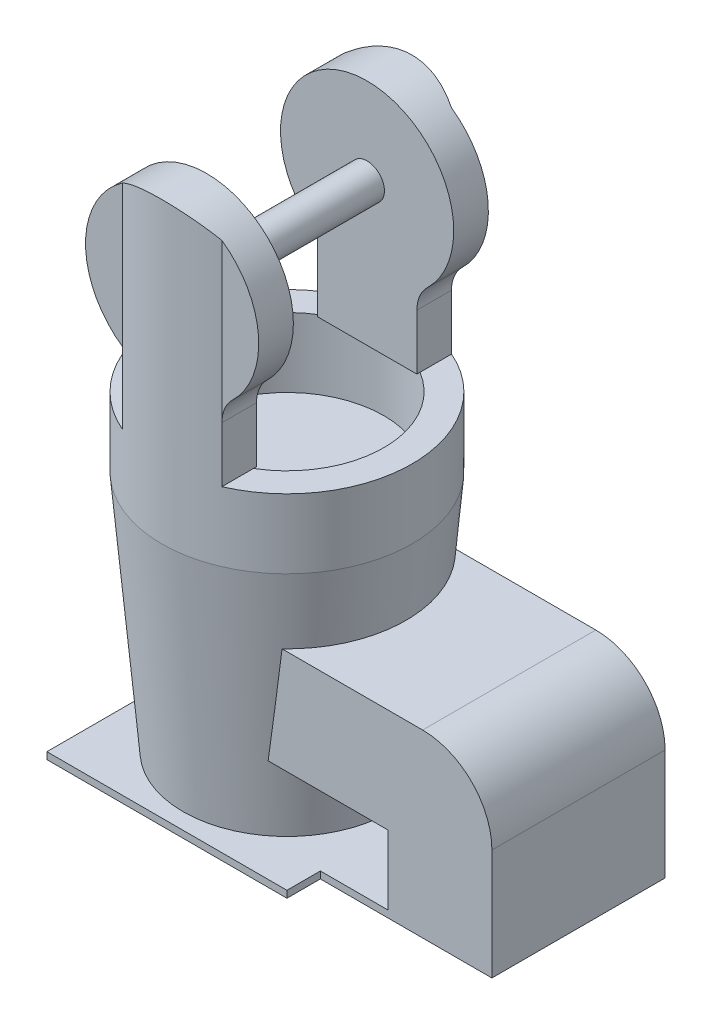
from build123d import *

# Parameters (mm, degrees)
SKETCH1_W                 = 69.296350976
SKETCH1_H                 = 69.296350976
SKETCH1_W_2               = 49.515978472
SKETCH1_H_2               = 50
BOSS_EXTRUDE1_DEPTH       = 2
SKETCH2_R                 = 30
BOSS_EXTRUDE2_DEPTH       = 70
BOSS_EXTRUDE2_TAPER       = -5
SKETCH3_R                 = 36.124206447
BOSS_EXTRUDE3_DEPTH       = 20
SKETCH4_R                 = 28
CUT_EXTRUDE2_DEPTH        = 20
SKETCH5_W                 = 30
SKETCH5_H                 = 50
BOSS_EXTRUDE4_DEPTH       = 50
SKETCH6_W                 = 50
SKETCH6_H                 = 30
BOSS_EXTRUDE5_DEPTH       = 40
FILLET1_R                 = 20
BOSS_EXTRUDE11_DEPTH      = 70
CUT_EXTRUDE22_DEPTH       = 70
CUT_EXTRUDE22_DEPTH_BACK  = 70
SKETCH22_R                = 5
BOSS_EXTRUDE12_DEPTH      = 51
BOSS_EXTRUDE12_DEPTH_BACK = 2


with BuildPart() as part:
    # Sketch1 → Boss-Extrude1 (new body)
    with BuildSketch(Plane(origin=(0, 0, 0), x_dir=(1, 0, 0), z_dir=(0, 1, 0))):
        Rectangle(SKETCH1_W, SKETCH1_H)
        with Locations((59.406164724, 0)):
            Rectangle(SKETCH1_W_2, SKETCH1_H_2)
    extrude(amount=BOSS_EXTRUDE1_DEPTH)

    # Sketch2 → Boss-Extrude2 (add)
    with BuildSketch(Plane(origin=(0, 2, 0), x_dir=(1, 0, 0), z_dir=(0, 1, 0))):
        Circle(SKETCH2_R)
    extrude(amount=BOSS_EXTRUDE2_DEPTH, taper=BOSS_EXTRUDE2_TAPER)

    # Sketch3 → Boss-Extrude3 (add)
    with BuildSketch(Plane(origin=(0, 72, 0), x_dir=(1, 0, 0), z_dir=(0, 1, 0))):
        Circle(SKETCH3_R)
    extrude(amount=BOSS_EXTRUDE3_DEPTH)

    # Sketch4 → Cut-Extrude2 (cut)
    with BuildSketch(Plane(origin=(0, 92, 0), x_dir=(1, 0, 0), z_dir=(0, 1, 0))):
        Circle(SKETCH4_R)
    extrude(amount=-CUT_EXTRUDE2_DEPTH, mode=Mode.SUBTRACT)

    # Sketch5 → Boss-Extrude4 (add)
    with BuildSketch(Plane(origin=(0, 2, 0), x_dir=(1, 0, 0), z_dir=(0, 1, 0))):
        with Locations((69.16415396, 0)):
            Rectangle(SKETCH5_W, SKETCH5_H)
    extrude(amount=BOSS_EXTRUDE4_DEPTH)

    # Sketch6 → Boss-Extrude5 (add)
    with BuildSketch(Plane.ZY.offset(-54.16415396)):
        with Locations((0, 37)):
            Rectangle(SKETCH6_W, SKETCH6_H)
    extrude(amount=BOSS_EXTRUDE5_DEPTH)

    # Fillet1
    fillet1_edges = [part.edges().sort_by_distance(p)[0] for p in [
        (84.16415396, 52, 0),
    ]]
    fillet(fillet1_edges, radius=FILLET1_R)

    # Sketch7 → Boss-Extrude11 (add)
    with BuildSketch(Plane(origin=(0, 92, 0), x_dir=(1, 0, 0), z_dir=(0, 1, 0))):
        with BuildLine():
            Line((27.734618886, 23.14625686), (38.570246087, 23.14625686))
            Line((38.570246087, 23.14625686), (38.570246087, 33.14625686))
            Line((38.570246087, 33.14625686), (14.36258847, 33.14625686))
            ThreePointArc((14.36258847, 33.14625686), (21.634318034, 28.929475879), (27.734618886, 23.14625686))
        make_face()
        with BuildLine():
            ThreePointArc((-14.36258847, 33.14625686), (-21.634318034, 28.929475879), (-27.734618886, 23.14625686))
            Line((-27.734618886, 23.14625686), (-15.755976433, 23.14625686))
            ThreePointArc((-15.755976433, 23.14625686), (0, 28), (15.755976433, 23.14625686))
            Line((15.755976433, 23.14625686), (27.734618886, 23.14625686))
            ThreePointArc((27.734618886, 23.14625686), (21.634318034, 28.929475879), (14.36258847, 33.14625686))
            Line((14.36258847, 33.14625686), (-14.36258847, 33.14625686))
        make_face()
        with BuildLine():
            Line((-37.772768209, 23.14625686), (-27.734618886, 23.14625686))
            ThreePointArc((-27.734618886, 23.14625686), (-21.634318034, 28.929475879), (-14.36258847, 33.14625686))
            Line((-14.36258847, 33.14625686), (-37.772768209, 33.14625686))
            Line((-37.772768209, 33.14625686), (-37.772768209, 23.14625686))
        make_face()
        with BuildLine():
            ThreePointArc((14.36258847, 33.14625686), (0, 36.124206447), (-14.36258847, 33.14625686))
            Line((-14.36258847, 33.14625686), (14.36258847, 33.14625686))
        make_face()
        with BuildLine():
            ThreePointArc((15.755976433, 23.14625686), (0, 28), (-15.755976433, 23.14625686))
            Line((-15.755976433, 23.14625686), (15.755976433, 23.14625686))
        make_face()
        with BuildLine():
            Line((-37.772768209, -33.14625686), (-14.36258847, -33.14625686))
            ThreePointArc((-14.36258847, -33.14625686), (-21.634318034, -28.929475879), (-27.734618886, -23.14625686))
            Line((-27.734618886, -23.14625686), (-37.772768209, -23.14625686))
            Line((-37.772768209, -23.14625686), (-37.772768209, -33.14625686))
        make_face()
        with BuildLine():
            Line((-14.36258847, -33.14625686), (14.36258847, -33.14625686))
            ThreePointArc((14.36258847, -33.14625686), (21.634318034, -28.929475879), (27.734618886, -23.14625686))
            Line((27.734618886, -23.14625686), (15.755976433, -23.14625686))
            ThreePointArc((15.755976433, -23.14625686), (0, -28), (-15.755976433, -23.14625686))
            Line((-15.755976433, -23.14625686), (-27.734618886, -23.14625686))
            ThreePointArc((-27.734618886, -23.14625686), (-21.634318034, -28.929475879), (-14.36258847, -33.14625686))
        make_face()
        with BuildLine():
            ThreePointArc((27.734618886, -23.14625686), (21.634318034, -28.929475879), (14.36258847, -33.14625686))
            Line((14.36258847, -33.14625686), (38.570246087, -33.14625686))
            Line((38.570246087, -33.14625686), (38.570246087, -23.14625686))
            Line((38.570246087, -23.14625686), (27.734618886, -23.14625686))
        make_face()
        with BuildLine():
            ThreePointArc((-15.755976433, -23.14625686), (0, -28), (15.755976433, -23.14625686))
            Line((15.755976433, -23.14625686), (-15.755976433, -23.14625686))
        make_face()
        with BuildLine():
            ThreePointArc((-14.36258847, -33.14625686), (0, -36.124206447), (14.36258847, -33.14625686))
            Line((14.36258847, -33.14625686), (-14.36258847, -33.14625686))
        make_face()
    extrude(amount=BOSS_EXTRUDE11_DEPTH)

    # Sketch20 → Cut-Extrude22 (cut, two sides)
    with BuildSketch(Plane.XY.offset(33.14625686)) as cut_extrude22_sk:
        with BuildLine():
            Line((-14.36258847, 92), (-14.36258847, 112.655146554))
            ThreePointArc((-14.36258847, 112.655146554), (-1.971914178, 158.039808748), (17.401848907, 115.168446794))
            ThreePointArc((17.401848907, 115.168446794), (15.153696147, 111.886989388), (14.36258847, 107.988745913))
            Line((14.36258847, 107.988745913), (14.36258847, 92))
            Line((14.36258847, 92), (38.570246087, 92))
            Line((38.570246087, 92), (38.570246087, 162))
            Line((38.570246087, 162), (-37.772768209, 162))
            Line((-37.772768209, 162), (-37.772768209, 92))
            Line((-37.772768209, 92), (-14.36258847, 92))
        make_face()
    extrude(amount=CUT_EXTRUDE22_DEPTH, mode=Mode.SUBTRACT)
    extrude(cut_extrude22_sk.sketch, amount=-CUT_EXTRUDE22_DEPTH_BACK, mode=Mode.SUBTRACT)

    # Sketch22 → Boss-Extrude12 (add, two sides)
    with BuildSketch(Plane.XY.offset(-23.14625686)) as boss_extrude12_sk:
        with Locations((0, 133.117698996)):
            Circle(SKETCH22_R)
    extrude(amount=BOSS_EXTRUDE12_DEPTH)
    extrude(boss_extrude12_sk.sketch, amount=-BOSS_EXTRUDE12_DEPTH_BACK)


solid = part.part
